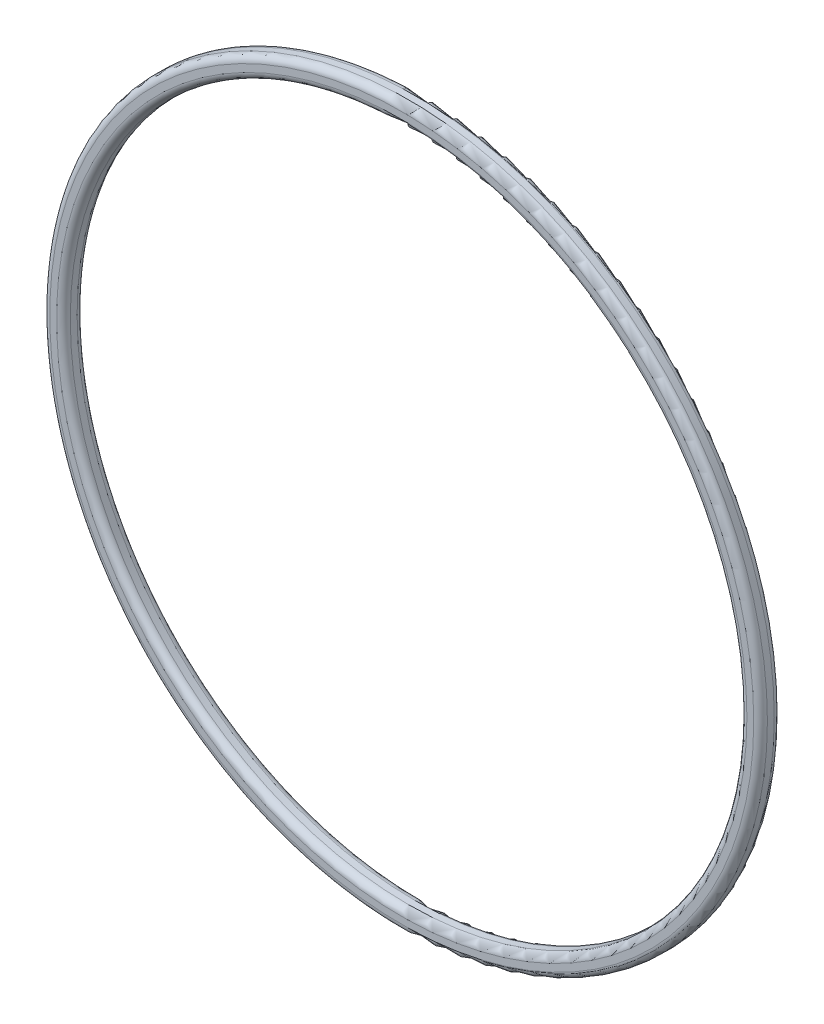
from build123d import *

# Parameters (mm, degrees)
SCHIZZO1_R                   = 52.5
SCHIZZO1_R_2                 = 49.5
ESTRUSIONE_ESTRUSIONE1_DEPTH = 3
RACCORDO1_R                  = 1


with BuildPart() as part:
    # Schizzo1 → Estrusione-Estrusione1 (new body)
    with BuildSketch(Plane.XY):
        Circle(SCHIZZO1_R)
        Circle(SCHIZZO1_R_2, mode=Mode.SUBTRACT)
    extrude(amount=ESTRUSIONE_ESTRUSIONE1_DEPTH)

    # Raccordo1
    raccordo1_edges = [part.edges().sort_by_distance(p)[0] for p in [
        (-52.5, 0, 0),
        (-52.5, 0, 3),
        (-49.5, 0, 0),
        (-49.5, 0, 3),
    ]]
    fillet(raccordo1_edges, radius=RACCORDO1_R)


solid = part.part
